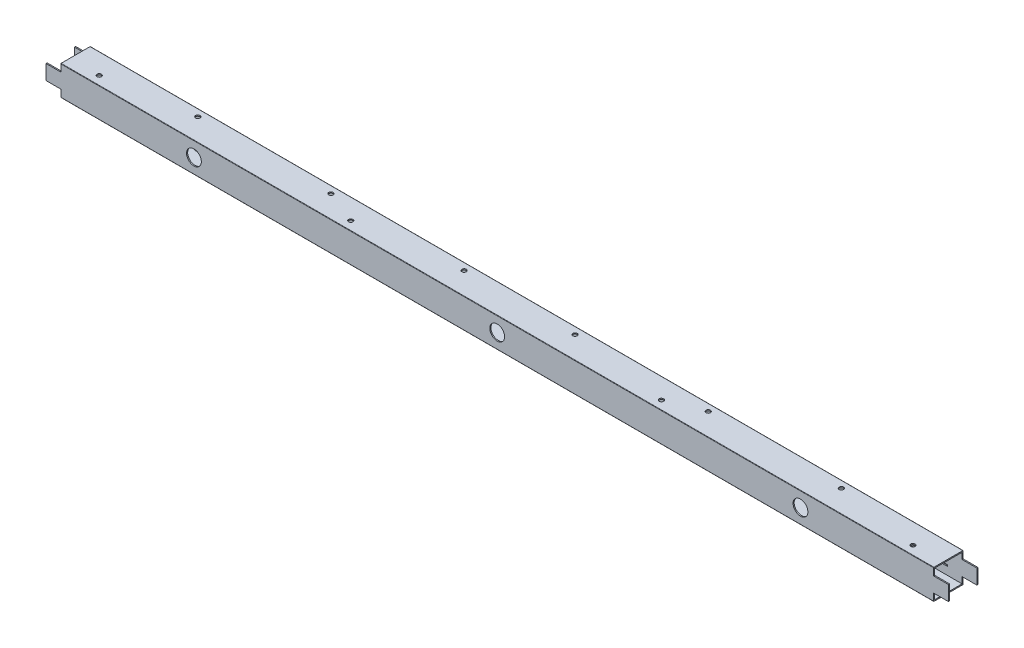
from build123d import *

# Parameters (mm, degrees)
SKETCH2_W               = 37
SKETCH2_H               = 37
BOSS_EXTRUDE1_DEPTH     = 1220
SKETCH3_W               = 20
SKETCH3_H               = 10
CUT_EXTRUDE1_DEPTH      = 50
SKETCH4_W               = 80
SKETCH4_H               = 2
SKETCH4_W_2             = 2
SKETCH4_H_2             = 6
CUT_EXTRUDE2_DEPTH      = 20
SKETCH5_R               = 10
CUT_EXTRUDE3_DEPTH      = 1222.310771262
CUT_EXTRUDE3_DEPTH_BACK = 1222.310771262
SKETCH6_R               = 3
CUT_EXTRUDE4_DEPTH      = 1222.310771262
SKETCH7_R               = 3
CUT_EXTRUDE5_DEPTH      = 1222.310771262


with BuildPart() as part:
    # Sketch2 → Boss-Extrude1 (new body)
    with BuildSketch(Plane(origin=(0, 0, 0), x_dir=(0, 0, -1), z_dir=(1, 0, 0))):
        with BuildLine():
            Line((0.5, 0), (39.5, 0))
            ThreePointArc((39.5, 0), (39.853553391, 0.146446609), (40, 0.5))
            Line((40, 0.5), (40, 39.5))
            ThreePointArc((40, 39.5), (39.853553391, 39.853553391), (39.5, 40))
            Line((39.5, 40), (0.5, 40))
            ThreePointArc((0.5, 40), (0.146446609, 39.853553391), (0, 39.5))
            Line((0, 39.5), (0, 0.5))
            ThreePointArc((0, 0.5), (0.146446609, 0.146446609), (0.5, 0))
        make_face()
        with Locations((20, 20)):
            Rectangle(SKETCH2_W, SKETCH2_H, mode=Mode.SUBTRACT)
    extrude(amount=BOSS_EXTRUDE1_DEPTH)

    # Sketch3 → Cut-Extrude1 (cut)
    with BuildSketch(Plane(origin=(0, 0, -40), x_dir=(-1, 0, 0), z_dir=(0, 0, -1))):
        with Locations((-1210, 35)):
            Rectangle(SKETCH3_W, SKETCH3_H)
        with Locations((-1210, 5)):
            Rectangle(SKETCH3_W, SKETCH3_H)
        with Locations((-10, 5)):
            Rectangle(SKETCH3_W, SKETCH3_H)
        with Locations((-10, 35)):
            Rectangle(SKETCH3_W, SKETCH3_H)
    extrude(amount=-CUT_EXTRUDE1_DEPTH, mode=Mode.SUBTRACT)

    # Sketch4 → Cut-Extrude2 (cut)
    with BuildSketch(Plane(origin=(0, 0, -40), x_dir=(-1, 0, 0), z_dir=(0, 0, -1))):
        with Locations((-80, 13)):
            Rectangle(SKETCH4_W, SKETCH4_H)
        with Locations((-134, 9)):
            Rectangle(SKETCH4_W_2, SKETCH4_H_2)
        with Locations((-1086, 9)):
            Rectangle(SKETCH4_W_2, SKETCH4_H_2)
        with Locations((-1140, 13)):
            Rectangle(SKETCH4_W, SKETCH4_H)
    extrude(amount=-CUT_EXTRUDE2_DEPTH, mode=Mode.SUBTRACT)

    # Sketch5 → Cut-Extrude3 (cut, two sides)
    with BuildSketch(Plane(origin=(0, 0, -40), x_dir=(-1, 0, 0), z_dir=(0, 0, -1))) as cut_extrude3_sk:
        with Locations(Location((-1020, 20, 0), (0, 0, 180))):
            Circle(SKETCH5_R)
        with Locations(Location((-610, 20, 0), (0, 0, 180))):
            Circle(SKETCH5_R)
        with Locations(Location((-200, 20, 0), (0, 0, 180))):
            Circle(SKETCH5_R)
    extrude(amount=CUT_EXTRUDE3_DEPTH, mode=Mode.SUBTRACT)
    extrude(cut_extrude3_sk.sketch, amount=-CUT_EXTRUDE3_DEPTH_BACK, mode=Mode.SUBTRACT)

    # Sketch6 → Cut-Extrude4 (cut, through all)
    with BuildSketch(Plane.XZ):
        with Locations(Location((1160, -12, 0), (0, 0, 270))):
            Circle(SKETCH6_R)
        with Locations(Location((820, -12, 0), (0, 0, 270))):
            Circle(SKETCH6_R)
        with Locations(Location((400, -12, 0), (0, 0, 270))):
            Circle(SKETCH6_R)
        with Locations(Location((60, -12, 0), (0, 0, 270))):
            Circle(SKETCH6_R)
    extrude(amount=-CUT_EXTRUDE4_DEPTH, mode=Mode.SUBTRACT)

    # Sketch7 → Cut-Extrude5 (cut, through all)
    with BuildSketch(Plane.XZ):
        with Locations(Location((1045, -30.25, 0), (0, 0, 270))):
            Circle(SKETCH7_R)
        with Locations(Location((865, -30.25, 0), (0, 0, 270))):
            Circle(SKETCH7_R)
        with Locations(Location((685, -30.25, 0), (0, 0, 270))):
            Circle(SKETCH7_R)
        with Locations(Location((535, -30.25, 0), (0, 0, 270))):
            Circle(SKETCH7_R)
        with Locations(Location((355, -30.25, 0), (0, 0, 270))):
            Circle(SKETCH7_R)
        with Locations(Location((175, -30.25, 0), (0, 0, 270))):
            Circle(SKETCH7_R)
    extrude(amount=-CUT_EXTRUDE5_DEPTH, mode=Mode.SUBTRACT)


solid = part.part
